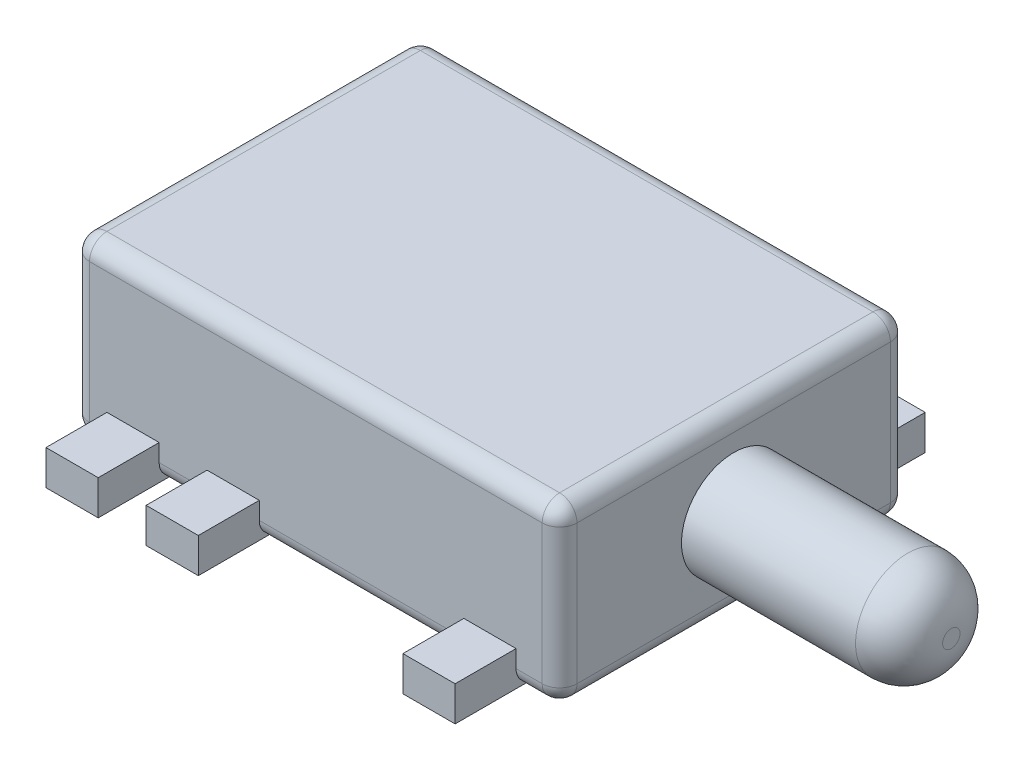
from build123d import *

# Parameters (mm, degrees)
SKETCH_1_W      = 5.6
SKETCH_1_H      = 4
EXTRUDE_1_DEPTH = 2
SKETCH_2_R      = 0.6
EXTRUDE_2_DEPTH = 2.5
FILLET_1_R      = 0.5
SKETCH_3_W      = 0.6
SKETCH_3_H      = 5.4
EXTRUDE_3_DEPTH = 0.4
SKETCH_4_R      = 0.4
EXTRUDE_4_DEPTH = 0.6
CHAMFER_1_SIZE  = 0.1
FILLET_2_R      = 0.2


with BuildPart() as part:
    # Эскиз1 → Бобышка-Вытянуть1 (new body)
    with BuildSketch(Plane(origin=(0, 0, 0), x_dir=(1, 0, 0), z_dir=(0, 1, 0))):
        Rectangle(SKETCH_1_W, SKETCH_1_H)
    extrude(amount=EXTRUDE_1_DEPTH)

    # Эскиз2 → Бобышка-Вытянуть2 (add)
    with BuildSketch(Plane(origin=(2.8, 0, 0), x_dir=(0, 0, -1), z_dir=(1, 0, 0))):
        with Locations((0, 1)):
            Circle(SKETCH_2_R)
    extrude(amount=EXTRUDE_2_DEPTH)

    # Скругление1
    fillet_1_edges = [part.edges().sort_by_distance(p)[0] for p in [
        (5.3, 1, 0.6),
    ]]
    fillet(fillet_1_edges, radius=FILLET_1_R)

    # Эскиз3 → Бобышка-Вытянуть3 (add)
    with BuildSketch(Plane.XZ):
        with Locations((-2.1, 0)):
            Rectangle(SKETCH_3_W, SKETCH_3_H)
        with Locations((-0.95, 0)):
            Rectangle(SKETCH_3_W, SKETCH_3_H)
        with Locations((2, 0)):
            Rectangle(SKETCH_3_W, SKETCH_3_H)
    extrude(amount=-EXTRUDE_3_DEPTH)

    # Эскиз4 → Бобышка-Вытянуть4 (add)
    with BuildSketch(Plane.XZ):
        with Locations((-1.45, 0)):
            Circle(SKETCH_4_R)
        with Locations((1.55, 0)):
            Circle(SKETCH_4_R)
    extrude(amount=EXTRUDE_4_DEPTH)

    # Фаска1
    chamfer_1_edges = [part.edges().sort_by_distance(p)[0] for p in [
        (-1.85, -0.6, 0),
        (1.15, -0.6, 0),
    ]]
    chamfer(chamfer_1_edges, length=CHAMFER_1_SIZE)

    # Скругление2
    fillet_2_edges = [part.edges().sort_by_distance(p)[0] for p in [
        (-2.8, 2, 0),
        (0, 2, 2),
        (-1.525, 0, 2),
        (-2.6, 0, -2),
        (2.8, 2, 0),
        (-1.525, 0, -2),
        (0.525, 0, 2),
        (-2.6, 0, 2),
        (-2.8, 0, 0),
        (2.55, 0, -2),
        (2.8, 0, 0),
        (0.525, 0, -2),
        (2.55, 0, 2),
        (0, 2, -2),
        (2.8, 1, 2),
        (-2.8, 1, 2),
        (-2.8, 1, -2),
        (2.8, 1, -2),
    ]]
    fillet(fillet_2_edges, radius=FILLET_2_R)


solid = part.part
